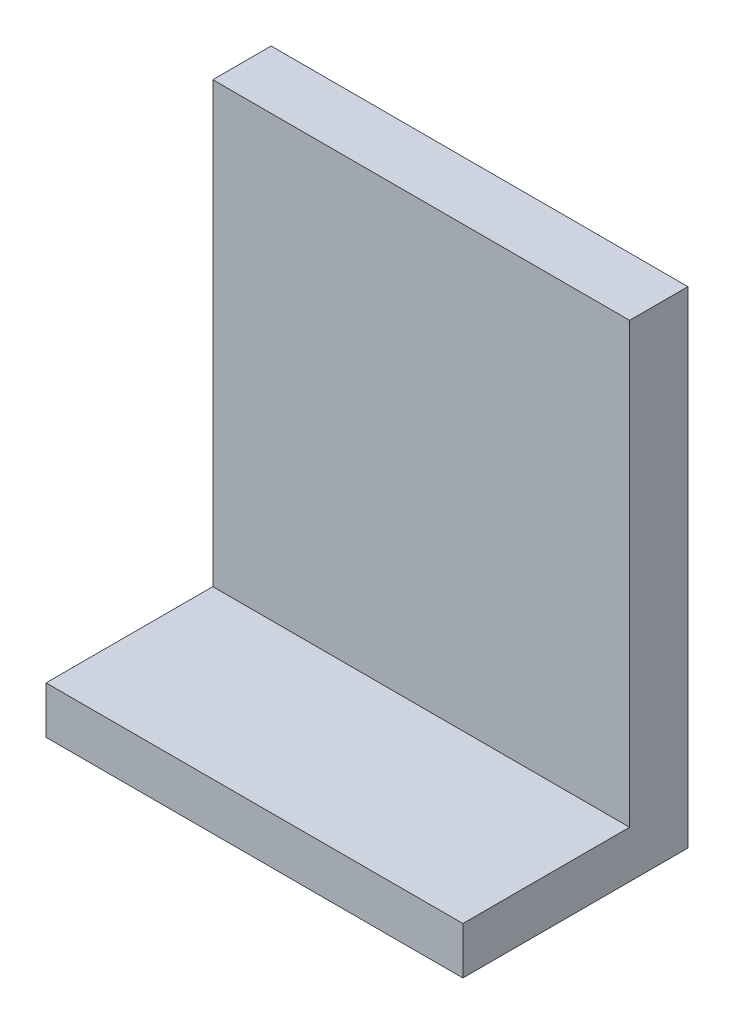
from build123d import *

# Parameters (mm, degrees)
SKETCH2_W           = 50
SKETCH2_H           = 58.319604613
BOSS_EXTRUDE1_DEPTH = 7
SKETCH3_W           = 50
SKETCH3_H           = 5.658443233
BOSS_EXTRUDE2_DEPTH = 20


with BuildPart() as part:
    # Sketch2 → Boss-Extrude1 (new body)
    with BuildSketch(Plane.XY):
        with Locations((25, -29.159802307)):
            Rectangle(SKETCH2_W, SKETCH2_H)
    extrude(amount=BOSS_EXTRUDE1_DEPTH)

    # Sketch3 → Boss-Extrude2 (add)
    with BuildSketch(Plane.XY.offset(7)):
        with Locations((25, -55.490382997)):
            Rectangle(SKETCH3_W, SKETCH3_H)
    extrude(amount=BOSS_EXTRUDE2_DEPTH)


solid = part.part
